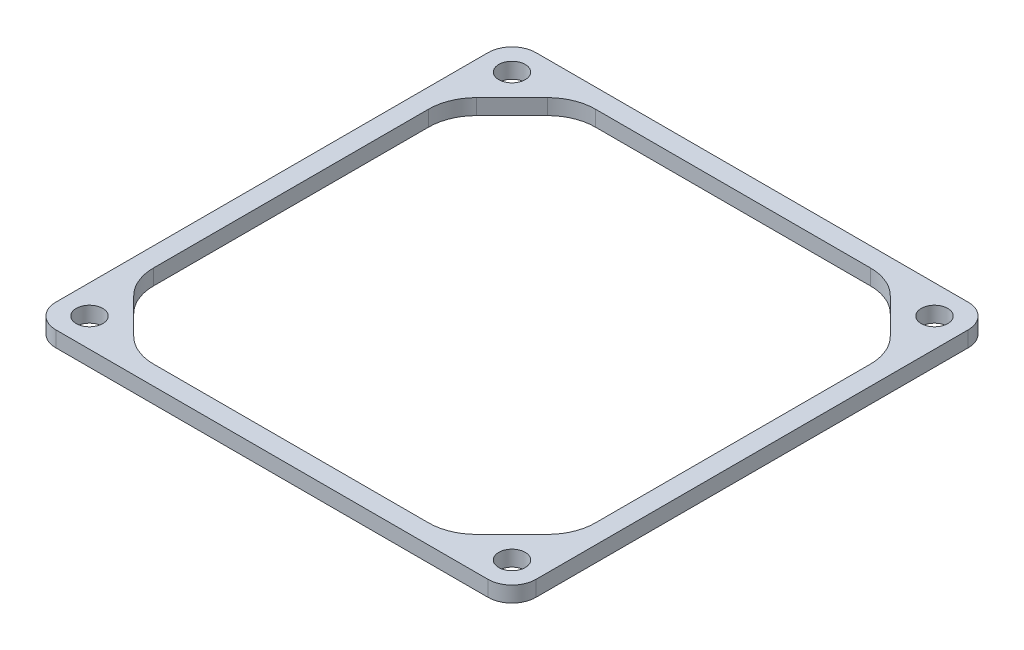
from build123d import *

# Parameters (mm, degrees)
SKETCH1_R                      = 44.45
SKETCH1_R_2                    = 3.25
BOSS_EXTRUDE1_DEPTH            = 3.175
BOSS_EXTRUDE2_DEPTH            = 25.4
CBORE_FOR_M6_SHCS2_D           = 7
CBORE_FOR_M6_SHCS2_CBORE_D     = 11
CBORE_FOR_M6_SHCS2_CBORE_DEPTH = 6
SKETCH10_W                     = 206.275362682
SKETCH10_H                     = 234.398565581
CUT_EXTRUDE1_DEPTH             = 15.2875
CUT_EXTRUDE1_DEPTH_BACK        = 10.16


with BuildPart() as part:
    # Sketch1 → Boss-Extrude1 (new body)
    with BuildSketch(Plane(origin=(0, 0, 0), x_dir=(1, 0, 0), z_dir=(0, 1, 0))):
        with BuildLine():
            Line((-57.15, 63.5), (57.15, 63.5))
            ThreePointArc((57.15, 63.5), (61.640128061, 61.640128061), (63.5, 57.15))
            Line((63.5, 57.15), (63.5, -57.15))
            ThreePointArc((63.5, -57.15), (61.640128061, -61.640128061), (57.15, -63.5))
            Line((57.15, -63.5), (-57.15, -63.5))
            ThreePointArc((-57.15, -63.5), (-61.640128061, -61.640128061), (-63.5, -57.15))
            Line((-63.5, -57.15), (-63.5, 57.15))
            ThreePointArc((-63.5, 57.15), (-61.640128061, 61.640128061), (-57.15, 63.5))
        make_face()
        Circle(SKETCH1_R, mode=Mode.SUBTRACT)
        with Locations((-57.15, 53.975)):
            Circle(SKETCH1_R_2, mode=Mode.SUBTRACT)
        with Locations((57.15, 53.975)):
            Circle(SKETCH1_R_2, mode=Mode.SUBTRACT)
        with Locations((57.15, -53.975)):
            Circle(SKETCH1_R_2, mode=Mode.SUBTRACT)
        with Locations((-57.15, -53.975)):
            Circle(SKETCH1_R_2, mode=Mode.SUBTRACT)
    extrude(amount=BOSS_EXTRUDE1_DEPTH)

    # Sketch3 → Boss-Extrude2 (add)
    with BuildSketch(Plane(origin=(0, 3.175, 0), x_dir=(1, 0, 0), z_dir=(0, 1, 0))):
        with BuildLine():
            Line((-57.15, -63.5), (57.15, -63.5))
            ThreePointArc((57.15, -63.5), (61.640128061, -61.640128061), (63.5, -57.15))
            Line((63.5, -57.15), (63.5, 57.15))
            ThreePointArc((63.5, 57.15), (61.640128061, 61.640128061), (57.15, 63.5))
            Line((57.15, 63.5), (-57.15, 63.5))
            ThreePointArc((-57.15, 63.5), (-61.640128061, 61.640128061), (-63.5, 57.15))
            Line((-63.5, 57.15), (-63.5, -57.15))
            ThreePointArc((-63.5, -57.15), (-61.640128061, -61.640128061), (-57.15, -63.5))
        make_face()
        with BuildLine():
            Line((-54.700256121, 45.358975516), (-45.358975516, 54.700256121))
            ThreePointArc((-45.358975516, 54.700256121), (-41.238798986, 57.453270063), (-36.378719395, 58.42))
            Line((-36.378719395, 58.42), (36.378719395, 58.42))
            ThreePointArc((36.378719395, 58.42), (41.238798986, 57.453270063), (45.358975516, 54.700256121))
            Line((45.358975516, 54.700256121), (54.700256121, 45.358975516))
            ThreePointArc((54.700256121, 45.358975516), (57.453270063, 41.238798986), (58.42, 36.378719395))
            Line((58.42, 36.378719395), (58.42, -36.378719395))
            ThreePointArc((58.42, -36.378719395), (57.453270063, -41.238798986), (54.700256121, -45.358975516))
            Line((54.700256121, -45.358975516), (45.358975516, -54.700256121))
            ThreePointArc((45.358975516, -54.700256121), (41.238798986, -57.453270063), (36.378719395, -58.42))
            Line((36.378719395, -58.42), (-36.378719395, -58.42))
            ThreePointArc((-36.378719395, -58.42), (-41.238798986, -57.453270063), (-45.358975516, -54.700256121))
            Line((-45.358975516, -54.700256121), (-54.700256121, -45.358975516))
            ThreePointArc((-54.700256121, -45.358975516), (-57.453270063, -41.238798986), (-58.42, -36.378719395))
            Line((-58.42, -36.378719395), (-58.42, 36.378719395))
            ThreePointArc((-58.42, 36.378719395), (-57.453270063, 41.238798986), (-54.700256121, 45.358975516))
        make_face(mode=Mode.SUBTRACT)
    extrude(amount=BOSS_EXTRUDE2_DEPTH)

    # CBORE for M6 SHCS2 (through all)
    with Locations(Plane(origin=(0, 0, 0), x_dir=(-1, 0, 0), z_dir=(0, -1, 0))):
        with Locations((-55.88, 55.88), (55.88, 55.88), (55.88, -55.88), (-55.88, -55.88)):
            CounterBoreHole(CBORE_FOR_M6_SHCS2_D / 2, CBORE_FOR_M6_SHCS2_CBORE_D / 2, CBORE_FOR_M6_SHCS2_CBORE_DEPTH)

    # Sketch10 → Cut-Extrude1 (cut, two sides)
    with BuildSketch(Plane(origin=(0, 14.2875, 0), x_dir=(-1, 0, 0), z_dir=(0, -1, 0))) as cut_extrude1_sk:
        with Locations((4.587579463, 2.84706708)):
            Rectangle(SKETCH10_W, SKETCH10_H)
    extrude(amount=CUT_EXTRUDE1_DEPTH, mode=Mode.SUBTRACT)
    extrude(cut_extrude1_sk.sketch, amount=-CUT_EXTRUDE1_DEPTH_BACK, mode=Mode.SUBTRACT)


solid = part.part
